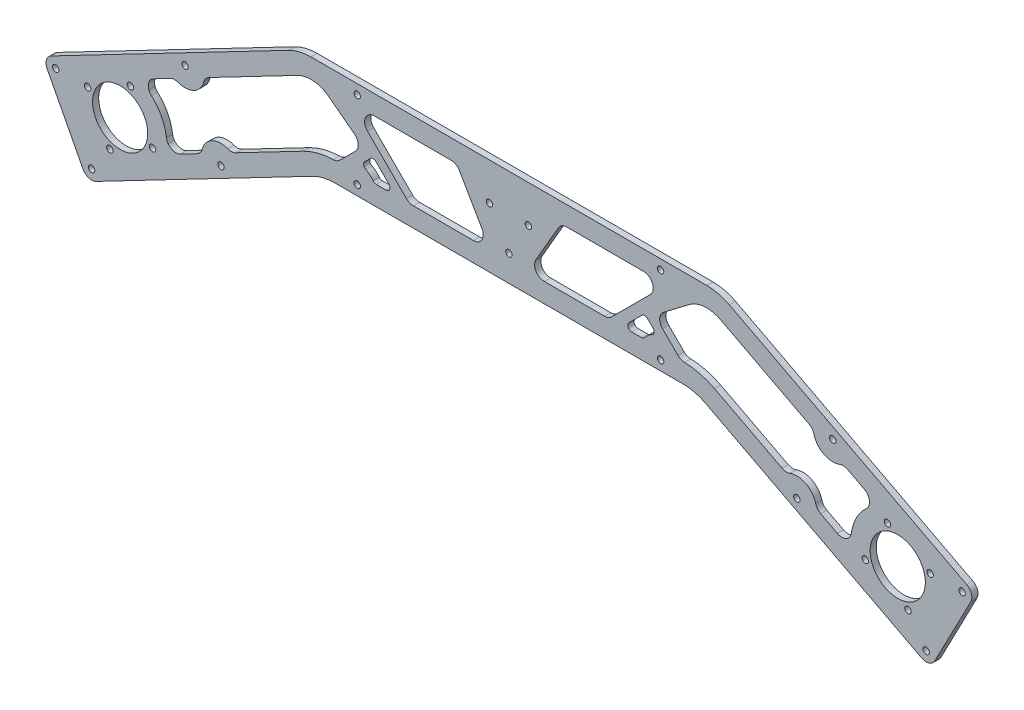
from build123d import *

# Parameters (mm, degrees)
SKETCH1_R              = 14.2
SKETCH1_R_2            = 1.65
BASE_DEPTH             = 3.175
SKETCH3_R              = 1.65
STRUT_HOLES_DEPTH      = 4.175
LIGHTENING_HOLES_DEPTH = 4.175


with BuildPart() as part:
    # Sketch1 → Base (new body)
    with BuildSketch(Plane.XY):
        with BuildLine():
            Line((-113.35576806, -30.824729171), (-235.437134887, -94.376266227))
            ThreePointArc((-235.437134887, -94.376266227), (-237.896976574, -97.307791395), (-237.563445987, -101.120063459))
            Line((-237.563445987, -101.120063459), (-219.093501457, -136.600496786))
            ThreePointArc((-219.093501457, -136.600496786), (-216.161976289, -139.060338474), (-212.349704225, -138.726807886))
            Line((-212.349704225, -138.726807886), (-101.120845899, -80.824729171))
            ThreePointArc((-101.120845899, -80.824729171), (-95.519277876, -78.716448255), (-89.577130568, -78))
            Line((-89.577130568, -78), (89.577130568, -78))
            ThreePointArc((89.577130568, -78), (95.519277876, -78.716448255), (101.120845899, -80.824729171))
            Line((101.120845899, -80.824729171), (212.349704225, -138.726807886))
            ThreePointArc((212.349704225, -138.726807886), (216.161976289, -139.060338474), (219.093501457, -136.600496786))
            Line((219.093501457, -136.600496786), (237.563445987, -101.120063459))
            ThreePointArc((237.563445987, -101.120063459), (237.896976574, -97.307791395), (235.437134887, -94.376266227))
            Line((235.437134887, -94.376266227), (113.35576806, -30.824729171))
            ThreePointArc((113.35576806, -30.824729171), (107.754200038, -28.716448255), (101.812052729, -28))
            Line((101.812052729, -28), (-101.812052729, -28))
            ThreePointArc((-101.812052729, -28), (-107.754200038, -28.716448255), (-113.35576806, -30.824729171))
        make_face()
        with Locations((-200, -104.11341011)):
            Circle(SKETCH1_R, mode=Mode.SUBTRACT)
        with Locations((-216.690046638, -98.851058619)):
            Circle(SKETCH1_R_2, mode=Mode.SUBTRACT)
        with Locations((-194.737648509, -87.423363472)):
            Circle(SKETCH1_R_2, mode=Mode.SUBTRACT)
        with Locations((-183.309953362, -109.375761602)):
            Circle(SKETCH1_R_2, mode=Mode.SUBTRACT)
        with Locations((-205.262351491, -120.803456748)):
            Circle(SKETCH1_R_2, mode=Mode.SUBTRACT)
        with Locations((205.262351491, -120.803456748)):
            Circle(SKETCH1_R_2, mode=Mode.SUBTRACT)
        with Locations((216.690046638, -98.851058619)):
            Circle(SKETCH1_R_2, mode=Mode.SUBTRACT)
        with Locations((194.737648509, -87.423363472)):
            Circle(SKETCH1_R_2, mode=Mode.SUBTRACT)
        with Locations((183.309953362, -109.375761602)):
            Circle(SKETCH1_R_2, mode=Mode.SUBTRACT)
        with Locations((200, -104.11341011)):
            Circle(SKETCH1_R, mode=Mode.SUBTRACT)
        with Locations((-10, -47.226497308)):
            Circle(SKETCH1_R_2, mode=Mode.SUBTRACT)
        with Locations((10, -47.226497308)):
            Circle(SKETCH1_R_2, mode=Mode.SUBTRACT)
        with Locations((0, -64.547005384)):
            Circle(SKETCH1_R_2, mode=Mode.SUBTRACT)
    extrude(amount=BASE_DEPTH)

    # Sketch3 → Strut Holes (cut, through all)
    with BuildSketch(Plane.XY.offset(3.175)):
        with Locations((-214.658447291, -134.29175372)):
            Circle(SKETCH3_R)
        with Locations((-148.132634803, -99.660607727)):
            Circle(SKETCH3_R)
        with Locations((-78.03119405, -73)):
            Circle(SKETCH3_R)
        with Locations((-78.03119405, -33)):
            Circle(SKETCH3_R)
        with Locations((-166.602579332, -64.1801744)):
            Circle(SKETCH3_R)
        with Locations((-233.128391821, -98.811320393)):
            Circle(SKETCH3_R)
        with Locations((233.128391821, -98.811320393)):
            Circle(SKETCH3_R)
        with Locations((166.602579332, -64.1801744)):
            Circle(SKETCH3_R)
        with Locations((78.03119405, -33)):
            Circle(SKETCH3_R)
        with Locations((78.03119405, -73)):
            Circle(SKETCH3_R)
        with Locations((148.132634803, -99.660607727)):
            Circle(SKETCH3_R)
        with Locations((214.658447291, -134.29175372)):
            Circle(SKETCH3_R)
    extrude(amount=-STRUT_HOLES_DEPTH, mode=Mode.SUBTRACT)

    # Sketch4 → Lightening Holes (cut, through all)
    with BuildSketch(Plane(origin=(0, 0, 0), x_dir=(-1, 0, 0), z_dir=(0, 0, -1))):
        with BuildLine():
            Line((-168.960154528, -104.865818506), (-160.358460468, -100.38806))
            ThreePointArc((-160.358460468, -100.38806), (-158.749015825, -99.059097441), (-157.82234729, -97.188873132))
            ThreePointArc((-157.82234729, -97.188873132), (-152.750120935, -90.790499395), (-144.599570492, -90.305531214))
            ThreePointArc((-144.599570492, -90.305531214), (-142.53605719, -90.619165384), (-140.52429527, -90.063047123))
            Line((-140.52429527, -90.063047123), (-105.738332031, -71.954620839))
            ThreePointArc((-105.738332031, -71.954620839), (-98.269905543, -69.096671797), (-90.347714306, -68.008483875))
            ThreePointArc((-90.347714306, -68.008483875), (-88.493641512, -67.607748759), (-86.922263791, -66.545229763))
            Line((-86.922263791, -66.545229763), (-79.009491694, -58.632457666))
            ThreePointArc((-79.009491694, -58.632457666), (-77.556385787, -54.760066484), (-79.516892411, -51.11817906))
            Line((-79.516892411, -51.11817906), (-92.727653164, -41.063765898))
            ThreePointArc((-92.727653164, -41.063765898), (-100.534196684, -38.054529652), (-108.738281928, -39.694837502))
            Line((-108.738281928, -39.694837502), (-154.376753667, -63.452722127))
            ThreePointArc((-154.376753667, -63.452722127), (-155.986198311, -64.781684686), (-156.912866845, -66.651908996))
            ThreePointArc((-156.912866845, -66.651908996), (-161.9850932, -73.050282732), (-170.135643643, -73.535250914))
            ThreePointArc((-170.135643643, -73.535250914), (-172.199156946, -73.221616743), (-174.210918865, -73.777735004))
            Line((-174.210918865, -73.777735004), (-182.812612925, -78.255493511))
            ThreePointArc((-182.812612925, -78.255493511), (-185.133676574, -80.802456106), (-185.255701497, -84.246213479))
            ThreePointArc((-185.255701497, -84.246213479), (-184.701637381, -85.374945921), (-183.883494983, -86.32975846))
            ThreePointArc((-183.883494983, -86.32975846), (-178.711740004, -93.031443393), (-176.188437881, -101.111825618))
            ThreePointArc((-176.188437881, -101.111825618), (-175.875568439, -102.329666609), (-175.268763073, -103.430943694))
            ThreePointArc((-175.268763073, -103.430943694), (-172.377811561, -105.306244811), (-168.960154528, -104.865818506))
        make_face()
        with BuildLine():
            Line((-68.284399705, -68), (-63.199367137, -68))
            ThreePointArc((-63.199367137, -68), (-61.351608072, -66.765366865), (-61.785153575, -64.585786438))
            Line((-61.785153575, -64.585786438), (-68.424239552, -57.946700461))
            ThreePointArc((-68.424239552, -57.946700461), (-69.838453114, -57.360914023), (-71.252666676, -57.946700461))
            Line((-71.252666676, -57.946700461), (-74.132142401, -60.826176185))
            ThreePointArc((-74.132142401, -60.826176185), (-74.691303243, -62.565648815), (-73.60347304, -64.033658123))
            ThreePointArc((-73.60347304, -64.033658123), (-71.563592326, -65.373065627), (-69.908865429, -67.166666667))
            ThreePointArc((-69.908865429, -67.166666667), (-69.197270634, -67.779513042), (-68.284399705, -68))
        make_face()
        with BuildLine():
            Line((-25.430550415, -40.5), (-13.883545032, -60.5))
            ThreePointArc((-13.883545032, -60.5), (-13.883545032, -65.5), (-18.21367205, -68))
            Line((-18.21367205, -68), (-49.228804389, -68))
            ThreePointArc((-49.228804389, -68), (-51.14222155, -67.619397663), (-52.764338294, -66.535533906))
            Line((-52.764338294, -66.535533906), (-72.764338294, -46.535533906))
            ThreePointArc((-72.764338294, -46.535533906), (-73.848202051, -41.086582838), (-69.228804389, -38))
            Line((-69.228804389, -38), (-29.760677434, -38))
            ThreePointArc((-29.760677434, -38), (-27.260677434, -38.669872981), (-25.430550415, -40.5))
        make_face()
        with BuildLine():
            Line((52.764338294, -66.535533906), (72.764338294, -46.535533906))
            ThreePointArc((72.764338294, -46.535533906), (73.848202051, -41.086582838), (69.228804389, -38))
            Line((69.228804389, -38), (29.760677434, -38))
            ThreePointArc((29.760677434, -38), (27.260677434, -38.669872981), (25.430550415, -40.5))
            Line((25.430550415, -40.5), (13.883545032, -60.5))
            ThreePointArc((13.883545032, -60.5), (13.883545032, -65.5), (18.21367205, -68))
            Line((18.21367205, -68), (49.228804389, -68))
            ThreePointArc((49.228804389, -68), (51.14222155, -67.619397663), (52.764338294, -66.535533906))
        make_face()
        with BuildLine():
            Line((68.284399705, -68), (63.199367137, -68))
            ThreePointArc((63.199367137, -68), (61.351608072, -66.765366865), (61.785153575, -64.585786438))
            Line((61.785153575, -64.585786438), (68.424239552, -57.946700461))
            ThreePointArc((68.424239552, -57.946700461), (69.838453114, -57.360914023), (71.252666676, -57.946700461))
            Line((71.252666676, -57.946700461), (74.132142401, -60.826176185))
            ThreePointArc((74.132142401, -60.826176185), (74.691303243, -62.565648815), (73.60347304, -64.033658123))
            ThreePointArc((73.60347304, -64.033658123), (71.563592326, -65.373065627), (69.908865429, -67.166666667))
            ThreePointArc((69.908865429, -67.166666667), (69.197270634, -67.779513042), (68.284399705, -68))
        make_face()
        with BuildLine():
            Line((154.376753667, -63.452722127), (108.738281928, -39.694837502))
            ThreePointArc((108.738281928, -39.694837502), (100.534196684, -38.054529652), (92.727653164, -41.063765898))
            Line((92.727653164, -41.063765898), (79.516892411, -51.11817906))
            ThreePointArc((79.516892411, -51.11817906), (77.556385787, -54.760066484), (79.009491694, -58.632457666))
            Line((79.009491694, -58.632457666), (86.922263791, -66.545229763))
            ThreePointArc((86.922263791, -66.545229763), (88.493641512, -67.607748759), (90.347714306, -68.008483875))
            ThreePointArc((90.347714306, -68.008483875), (98.269905543, -69.096671797), (105.738332031, -71.954620839))
            Line((105.738332031, -71.954620839), (140.52429527, -90.063047123))
            ThreePointArc((140.52429527, -90.063047123), (142.53605719, -90.619165384), (144.599570492, -90.305531214))
            ThreePointArc((144.599570492, -90.305531214), (152.750120935, -90.790499395), (157.82234729, -97.188873132))
            ThreePointArc((157.82234729, -97.188873132), (158.749015825, -99.059097441), (160.358460468, -100.38806))
            Line((160.358460468, -100.38806), (168.960154528, -104.865818506))
            ThreePointArc((168.960154528, -104.865818506), (172.377811561, -105.306244811), (175.268763073, -103.430943694))
            ThreePointArc((175.268763073, -103.430943694), (175.875568439, -102.329666609), (176.188437881, -101.111825618))
            ThreePointArc((176.188437881, -101.111825618), (178.711740004, -93.031443393), (183.883494983, -86.32975846))
            ThreePointArc((183.883494983, -86.32975846), (184.701637381, -85.374945921), (185.255701497, -84.246213479))
            ThreePointArc((185.255701497, -84.246213479), (185.133676574, -80.802456106), (182.812612925, -78.255493511))
            Line((182.812612925, -78.255493511), (174.210918865, -73.777735004))
            ThreePointArc((174.210918865, -73.777735004), (172.199156946, -73.221616743), (170.135643643, -73.535250914))
            ThreePointArc((170.135643643, -73.535250914), (161.9850932, -73.050282732), (156.912866845, -66.651908996))
            ThreePointArc((156.912866845, -66.651908996), (155.986198311, -64.781684686), (154.376753667, -63.452722127))
        make_face()
    extrude(amount=-LIGHTENING_HOLES_DEPTH, mode=Mode.SUBTRACT)


solid = part.part
